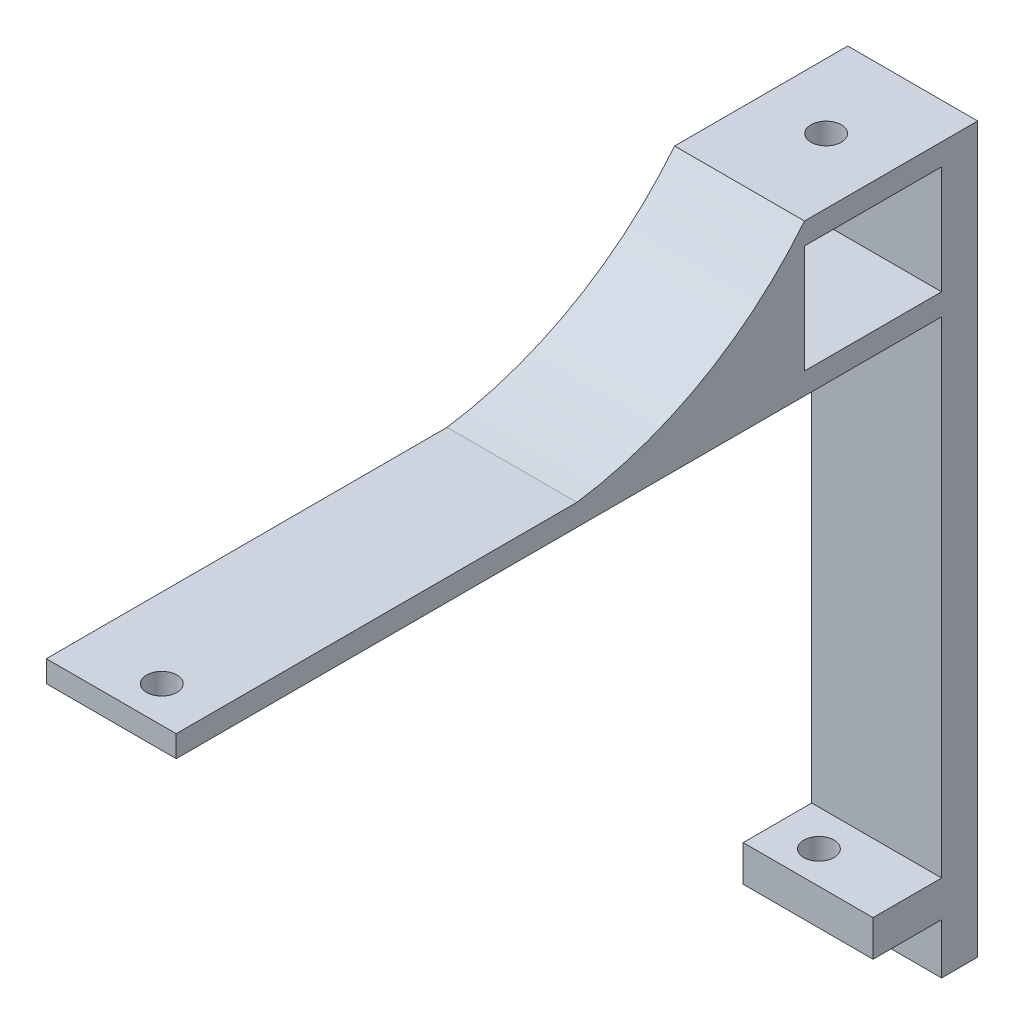
from build123d import *

# Parameters (mm, degrees)
SKETCH4_W           = 106.06440689
SKETCH4_H           = 3
SKETCH4_W_2         = 10
SKETCH4_H_2         = 5
BOSS_EXTRUDE1_DEPTH = 52
SKETCH5_R           = 2.1
CUT_EXTRUDE1_DEPTH  = 52
SKETCH6_R           = 2.1
CUT_EXTRUDE2_DEPTH  = 52
SKETCH7_W           = 16
SKETCH7_H           = 82.35034403
CUT_EXTRUDE4_DEPTH  = 124
BOSS_EXTRUDE2_DEPTH = 18
SKETCH9_R           = 2.1
CUT_EXTRUDE5_DEPTH  = 6
BOSS_EXTRUDE3_DEPTH = 18
SKETCH12_R          = 2.1
CUT_EXTRUDE7_DEPTH  = 11
SKETCH13_W          = 30.758926903
SKETCH13_H          = 118.81058029
CUT_EXTRUDE8_DEPTH  = 134
SKETCH14_W          = 18
SKETCH14_H          = 10
BOSS_EXTRUDE4_DEPTH = 5
SKETCH15_R          = 2.1
CUT_EXTRUDE9_DEPTH  = 10
SKETCH16_R          = 2.1
BOSS_EXTRUDE5_DEPTH = 3
SKETCH17_R          = 2.1
CUT_EXTRUDE10_DEPTH = 68
SKETCH18_W          = 18
SKETCH18_H          = 0.5
CUT_EXTRUDE11_DEPTH = 68
SKETCH19_W          = 7.063819309
SKETCH19_H          = 5.572840252
BOSS_EXTRUDE6_DEPTH = 5
SKETCH20_R          = 2.1
CUT_EXTRUDE12_DEPTH = 10


with BuildPart() as part:
    # Sketch4 → Boss-Extrude1 (new body)
    with BuildSketch(Plane(origin=(0, 0, 0), x_dir=(0, 0, -1), z_dir=(1, 0, 0))):
        with Locations((-20.39261819, 190.914352888)):
            Rectangle(SKETCH4_W, SKETCH4_H)
        Polygon((32.639585255, 189.414352888), (32.639585255, 122.064008858), (32.639585255, 117.064008858), (32.639585255, 110.064008858), (37.639585255, 110.064008858), (37.639585255, 192.414352888), (32.639585255, 192.414352888), align=None)
        with Locations((27.639585255, 119.564008858)):
            Rectangle(SKETCH4_W_2, SKETCH4_H_2)
    extrude(amount=BOSS_EXTRUDE1_DEPTH)

    # Sketch5 → Cut-Extrude1 (cut)
    with BuildSketch(Plane(origin=(0, 122.064008858, 0), x_dir=(1, 0, 0), z_dir=(0, 1, 0))):
        with Locations((6, 27.049585255)):
            Circle(SKETCH5_R)
        with Locations((46, 27.639585255)):
            Circle(SKETCH5_R)
    extrude(amount=-CUT_EXTRUDE1_DEPTH, mode=Mode.SUBTRACT)

    # Sketch6 → Cut-Extrude2 (cut)
    with BuildSketch(Plane(origin=(0, 192.414352888, 0), x_dir=(1, 0, 0), z_dir=(0, 1, 0))):
        with Locations((41, -68.424821635)):
            Circle(SKETCH6_R)
        with Locations((11, -68.424821635)):
            Circle(SKETCH6_R)
    extrude(amount=-CUT_EXTRUDE2_DEPTH, mode=Mode.SUBTRACT)

    # Sketch7 → Cut-Extrude4 (cut)
    with BuildSketch(Plane(origin=(0, 0, -37.639585255), x_dir=(-1, 0, 0), z_dir=(0, 0, -1))):
        with Locations((-26, 151.239180873)):
            Rectangle(SKETCH7_W, SKETCH7_H)
    extrude(amount=-CUT_EXTRUDE4_DEPTH, mode=Mode.SUBTRACT)

    # Sketch8 → Boss-Extrude2 (add)
    with BuildSketch(Plane.ZY):
        with BuildLine():
            Line((-37.639585255, 210.414352888), (-37.639585255, 192.414352888))
            Line((-37.639585255, 192.414352888), (-32.639585255, 192.414352888))
            Line((-32.639585255, 192.414352888), (-32.639585255, 207.414352888))
            Line((-32.639585255, 207.414352888), (-13.639585255, 207.414352888))
            Line((-13.639585255, 207.414352888), (-13.639585255, 192.414352888))
            Line((-13.639585255, 192.414352888), (17.89261819, 192.414352888))
            ThreePointArc((17.89261819, 192.414352888), (0.423706042, 198.431388178), (-13.639585255, 210.414352888))
            Line((-13.639585255, 210.414352888), (-37.639585255, 210.414352888))
        make_face()
    extrude(amount=-BOSS_EXTRUDE2_DEPTH)

    # Sketch9 → Cut-Extrude5 (cut)
    with BuildSketch(Plane(origin=(0, 210.414352888, 0), x_dir=(1, 0, 0), z_dir=(0, 1, 0))):
        with Locations((9, 25.639585255)):
            Circle(SKETCH9_R)
    extrude(amount=-CUT_EXTRUDE5_DEPTH, mode=Mode.SUBTRACT)

    # Sketch11 → Boss-Extrude3 (add)
    with BuildSketch(Plane(origin=(52, 0, 0), x_dir=(0, 0, -1), z_dir=(1, 0, 0))):
        with BuildLine():
            Line((32.639585255, 192.414352888), (37.639585255, 192.414352888))
            Line((37.639585255, 192.414352888), (37.639585255, 210.414352888))
            Line((37.639585255, 210.414352888), (13.639585255, 210.414352888))
            ThreePointArc((13.639585255, 210.414352888), (-0.423706042, 198.431388178), (-17.89261819, 192.414352888))
            Line((-17.89261819, 192.414352888), (13.639585255, 192.414352888))
            Line((13.639585255, 192.414352888), (13.639585255, 207.414352888))
            Line((13.639585255, 207.414352888), (32.639585255, 207.414352888))
            Line((32.639585255, 207.414352888), (32.639585255, 192.414352888))
        make_face()
    extrude(amount=-BOSS_EXTRUDE3_DEPTH)

    # Sketch12 → Cut-Extrude7 (cut)
    with BuildSketch(Plane(origin=(0, 210.414352888, 0), x_dir=(1, 0, 0), z_dir=(0, 1, 0))):
        with Locations((43, 25.639585255)):
            Circle(SKETCH12_R)
    extrude(amount=-CUT_EXTRUDE7_DEPTH, mode=Mode.SUBTRACT)

    # Sketch13 → Cut-Extrude8 (cut)
    with BuildSketch(Plane(origin=(0, 210.414352888, 0), x_dir=(1, 0, 0), z_dir=(0, 1, 0))):
        with Locations((9.143188102, -17.675085242)):
            Rectangle(SKETCH13_W, SKETCH13_H)
    extrude(amount=-CUT_EXTRUDE8_DEPTH, mode=Mode.SUBTRACT)

    # Sketch14 → Boss-Extrude4 (add)
    with BuildSketch(Plane(origin=(0, 122.064008858, 0), x_dir=(1, 0, 0), z_dir=(0, 1, 0))):
        with Locations((43, 27.639585255)):
            Rectangle(SKETCH14_W, SKETCH14_H)
    extrude(amount=-BOSS_EXTRUDE4_DEPTH)

    # Sketch15 → Cut-Extrude9 (cut)
    with BuildSketch(Plane(origin=(0, 122.064008858, 0), x_dir=(1, 0, 0), z_dir=(0, 1, 0))):
        with Locations((40, 27.049585255)):
            Circle(SKETCH15_R)
    extrude(amount=-CUT_EXTRUDE9_DEPTH, mode=Mode.SUBTRACT)

    # Sketch16 → Boss-Extrude5 (add)
    with BuildSketch(Plane(origin=(0, 192.414352888, 0), x_dir=(1, 0, 0), z_dir=(0, 1, 0))):
        with Locations((41, -68.424821635)):
            Circle(SKETCH16_R)
    extrude(amount=-BOSS_EXTRUDE5_DEPTH)

    # Sketch17 → Cut-Extrude10 (cut)
    with BuildSketch(Plane(origin=(0, 192.414352888, 0), x_dir=(1, 0, 0), z_dir=(0, 1, 0))):
        with Locations((45, -68.424821635)):
            Circle(SKETCH17_R)
    extrude(amount=-CUT_EXTRUDE10_DEPTH, mode=Mode.SUBTRACT)

    # Sketch18 → Cut-Extrude11 (cut)
    with BuildSketch(Plane(origin=(0, 122.064008858, 0), x_dir=(1, 0, 0), z_dir=(0, 1, 0))):
        with Locations((43, 22.889585255)):
            Rectangle(SKETCH18_W, SKETCH18_H)
    extrude(amount=-CUT_EXTRUDE11_DEPTH, mode=Mode.SUBTRACT)

    # Sketch19 → Boss-Extrude6 (add)
    with BuildSketch(Plane(origin=(0, 122.064008858, 0), x_dir=(1, 0, 0), z_dir=(0, 1, 0))):
        with Locations((40.335863312, 27.294676588)):
            Rectangle(SKETCH19_W, SKETCH19_H)
    extrude(amount=-BOSS_EXTRUDE6_DEPTH)

    # Sketch20 → Cut-Extrude12 (cut)
    with BuildSketch(Plane(origin=(0, 122.064008858, 0), x_dir=(1, 0, 0), z_dir=(0, 1, 0))):
        with Locations((40, 27.639585255)):
            Circle(SKETCH20_R)
    extrude(amount=-CUT_EXTRUDE12_DEPTH, mode=Mode.SUBTRACT)


solid = part.part
